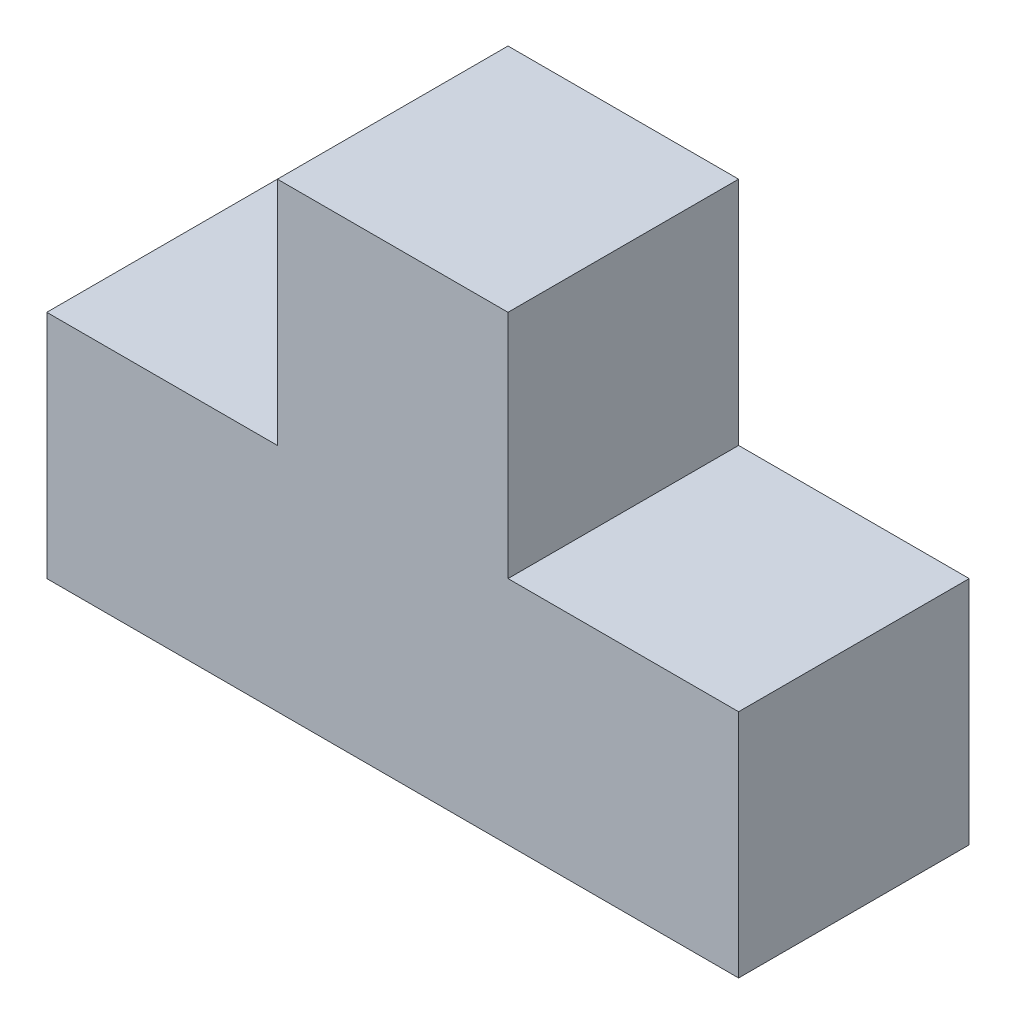
from build123d import *

# Parameters (mm, degrees)
BOSS_EXTRU_1_DEPTH = 30


with BuildPart() as part:
    # Esquisse1 → Boss.-Extru.1 (new body)
    with BuildSketch(Plane.XY):
        Polygon((0, 0), (90, 0), (90, 30), (60, 30), (60, 60), (30, 60), (30, 30), (0, 30), align=None)
    extrude(amount=BOSS_EXTRU_1_DEPTH)


solid = part.part
